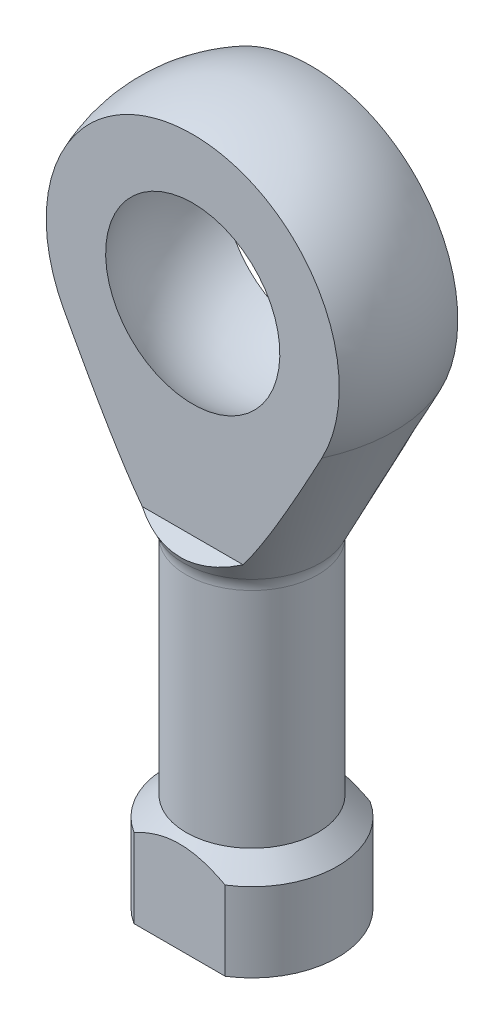
from build123d import *

# Parameters (mm, degrees)
SKETCH_5_R          = 1.5
CUT_EXTRUDE_2_DEPTH = 10
CUT_EXTRUDE_3_DEPTH = 10
SKETCH_7_W          = 6.5
SKETCH_7_H          = 3.804727479
CUT_EXTRUDE_4_DEPTH = 29.301943396


with BuildPart() as part:
    # 草图2 → 旋转3 (revolve)
    with BuildSketch(Plane.XY):
        with BuildLine():
            Line((0, 0), (0, 27))
            ThreePointArc((0, 27), (-5.088288577, 24.179515585), (-5.392764278, 18.369773119))
            Line((-5.392764278, 18.369773119), (-2.601205954, 12.646230363))
            ThreePointArc((-2.601205954, 12.646230363), (-2.525629935, 12.432810271), (-2.5, 12.207859217))
            Line((-2.5, 12.207859217), (-2.5, 3.733696482))
            Line((-2.5, 3.733696482), (-3.25, 3))
            Line((-3.25, 3), (-3.25, 0))
            Line((-3.25, 0), (0, 0))
        make_face()
    revolve(axis=Axis((0, 35.781008953, 0), (0, -1, 0)))

    # 草图3 → 切除-旋转1 (revolve, cut)
    with BuildSketch(Plane(origin=(0, 0, 0), x_dir=(0, 0, -1), z_dir=(1, 0, 0))):
        with BuildLine():
            Line((0, 25), (0, 17))
            ThreePointArc((0, 17), (-4, 21), (0, 25))
        make_face()
    revolve(axis=Axis((0, 25, 0), (0, -1, 0)), mode=Mode.SUBTRACT)

    # 草图5 → 切除-拉伸2 (cut)
    with BuildSketch(Plane.XZ):
        Circle(SKETCH_5_R)
    extrude(amount=-CUT_EXTRUDE_2_DEPTH, mode=Mode.SUBTRACT)

    # 草图6 → 切除-拉伸3 (cut, symmetric)
    with BuildSketch(Plane(origin=(0, 0, 0), x_dir=(0, 0, -1), z_dir=(1, 0, 0))):
        Polygon((2.25, 28.432363899), (2.25, 13.369773119), (10.25, 5.369773119), (10.25, 28.432363899), align=None)
    cut_extrude_3 = extrude(amount=CUT_EXTRUDE_3_DEPTH, both=True, mode=Mode.SUBTRACT)

    # 镜向1: 切除-拉伸3 across plane
    add(cut_extrude_3.mirror(Plane.XY), mode=Mode.SUBTRACT)

    # 草图7 → 切除-拉伸4 (cut, through all)
    with BuildSketch(Plane.XY.offset(2.75)):
        with Locations((0, 1.90236374)):
            Rectangle(SKETCH_7_W, SKETCH_7_H)
    cut_extrude_4 = extrude(amount=CUT_EXTRUDE_4_DEPTH, mode=Mode.SUBTRACT)

    # 镜向2: 切除-拉伸4 across plane
    add(cut_extrude_4.mirror(Plane.XY), mode=Mode.SUBTRACT)


solid = part.part
